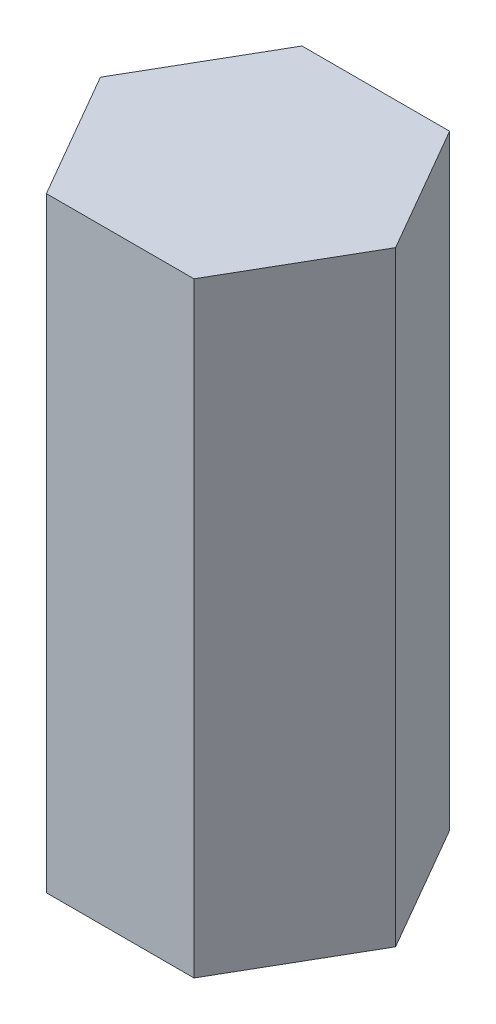
from build123d import *

# Parameters (mm, degrees)
BOSS_EXTRUDE1_DEPTH = 40


with BuildPart() as part:
    # Sketch1 → Boss-Extrude1 (new, symmetric)
    with BuildSketch(Plane(origin=(0, 0, 0), x_dir=(1, 0, 0), z_dir=(0, 1, 0))):
        Polygon((19.5, 0), (9.75, 16.887495374), (-9.75, 16.887495374), (-19.5, 0), (-9.75, -16.887495374), (9.75, -16.887495374), align=None)
    extrude(amount=BOSS_EXTRUDE1_DEPTH, both=True)


solid = part.part
